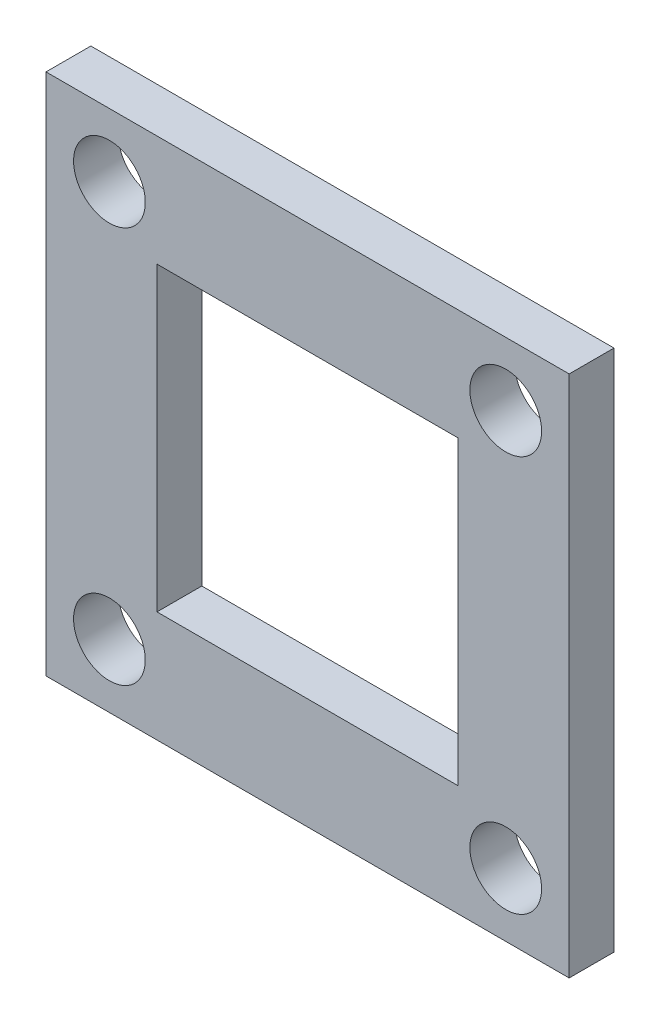
from build123d import *

# Parameters (mm, degrees)
SKETCH1_W           = 23.33452378
SKETCH1_H           = 23.33452378
SKETCH1_W_2         = 13.435028842
SKETCH1_H_2         = 13.435028842
BOSS_EXTRUDE1_DEPTH = 1
SKETCH2_R           = 1.6
CUT_EXTRUDE1_DEPTH  = 3


with BuildPart() as part:
    # Sketch1 → Boss-Extrude1 (new body, symmetric)
    with BuildSketch(Plane.XY):
        Rectangle(SKETCH1_W, SKETCH1_H)
        Rectangle(SKETCH1_W_2, SKETCH1_H_2, mode=Mode.SUBTRACT)
    extrude(amount=BOSS_EXTRUDE1_DEPTH, both=True)

    # Sketch2 → Cut-Extrude1 (cut, through all)
    with BuildSketch(Plane(origin=(0, 0, -1), x_dir=(-1, 0, 0), z_dir=(0, 0, -1))):
        with Locations((8.838834765, -8.838834765)):
            Circle(SKETCH2_R)
        with Locations((8.838834765, 8.838834765)):
            Circle(SKETCH2_R)
        with Locations((-8.838834765, -8.838834765)):
            Circle(SKETCH2_R)
        with Locations((-8.838834765, 8.838834765)):
            Circle(SKETCH2_R)
    extrude(amount=-CUT_EXTRUDE1_DEPTH, mode=Mode.SUBTRACT)


solid = part.part
